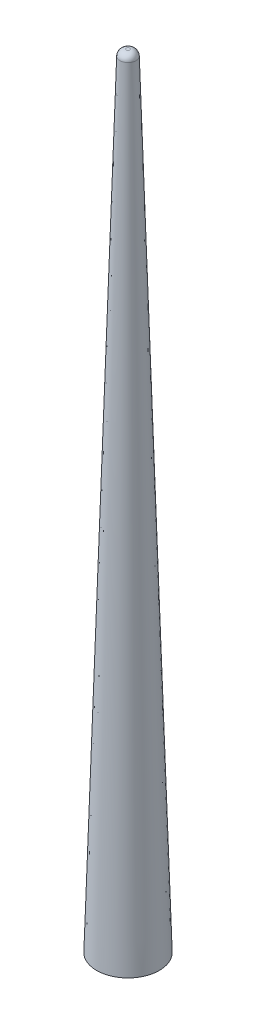
from build123d import *

# Parameters (mm, degrees)
SKETCH2_R = 10
SKETCH1_R = 2.5
FILLET1_R = 2


with BuildPart() as part:
    # Sketch2 → Loft1 section 0
    with BuildSketch(Plane(origin=(0, 0, 0), x_dir=(1, 0, 0), z_dir=(0, 1, 0))):
        Circle(SKETCH2_R)
    # Sketch1 → Loft1 section 1
    with BuildSketch(Plane(origin=(0, 250, 0), x_dir=(1, 0, 0), z_dir=(0, 1, 0))):
        Circle(SKETCH1_R)
    loft()

    # Fillet1
    fillet1_edges = [part.edges().sort_by_distance(p)[0] for p in [
        (-2.5, 250, 0),
    ]]
    fillet(fillet1_edges, radius=FILLET1_R)


solid = part.part
